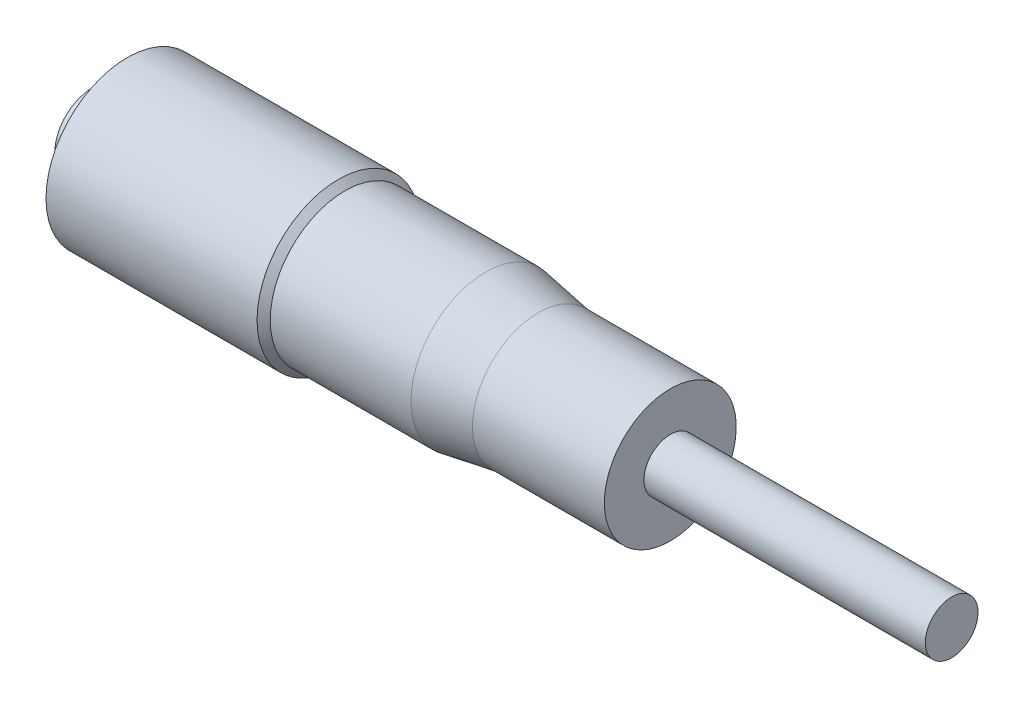
from build123d import *


with BuildPart() as part:
    # Sketch1 → Revolve1 (revolve)
    with BuildSketch(Plane.XY):
        with BuildLine():
            Line((-49.375, 0), (49.375, 0))
            Line((49.375, 0), (49.375, 3))
            Line((49.375, 3), (17.375, 3))
            Line((17.375, 3), (17.375, 7.5))
            Line((17.375, 7.5), (2.375, 7.5))
            Line((2.375, 7.5), (-3.625, 8.5))
            Line((-3.625, 8.5), (-19.625, 8.5))
            Line((-19.625, 8.5), (-20.375, 9.25))
            Line((-20.375, 9.25), (-44.375, 9.25))
            Line((-44.375, 9.25), (-45.875, 4.25))
            Line((-45.875, 4.25), (-48.375, 4.25))
            ThreePointArc((-48.375, 4.25), (-49.121632386, 2.18303115), (-49.375, 0))
        make_face()
    revolve(axis=Axis((0, 0, 0), (1, 0, 0)))


solid = part.part
